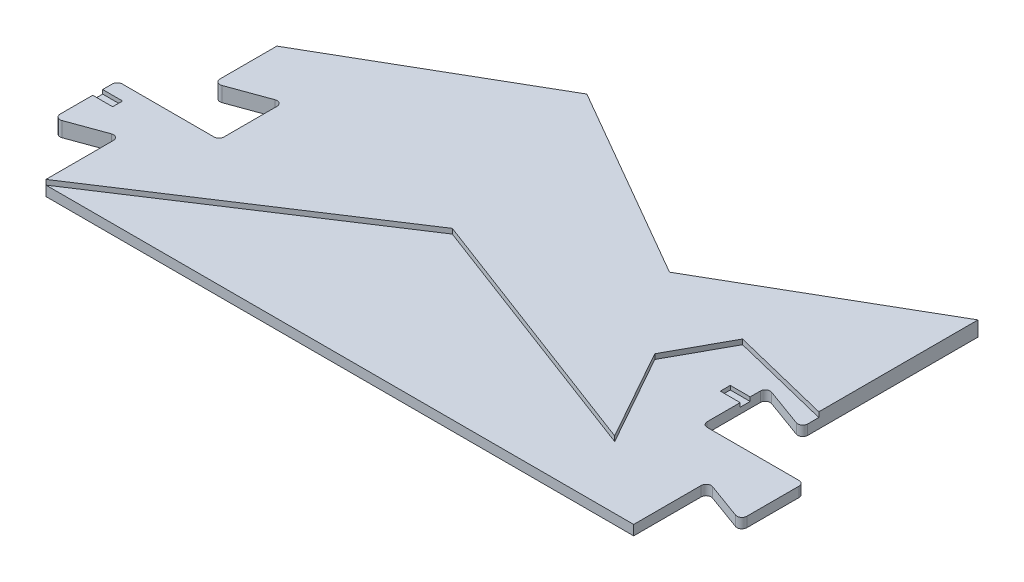
from build123d import *

# Parameters (mm, degrees)
P_IDAT_VYSUNUT_M1_DEPTH  = 3
P_IDAT_VYSUNUT_M2_DEPTH  = 2
ZAOBLIT4_R               = 1
SKICA2_W                 = 4
SKICA2_H                 = 2
ODEBRAT_VYSUNUT_M2_DEPTH = 0.8
SKICA3_W                 = 4
SKICA3_H                 = 2
ODEBRAT_VYSUNUT_M3_DEPTH = 0.8


with BuildPart() as part:
    # Skica1 → P_idat vysunut_m1 (new body)
    with BuildSketch(Plane(origin=(0, 0, 0), x_dir=(1, 0, 0), z_dir=(0, 1, 0))):
        Polygon((-118.143750166, 15), (-118.143750166, 0), (-68.779346971, 32.313398106), (-16.32734533, 12.51119421), (-26.593132493, 30.830954414), (-20.343228113, 42.230019956), (0, 37.22), (0, 69.22), (-39.317553332, 46.52), (-78.635106664, 69.22), (-118.143185584, 46.41), (-118.143185584, 33.5570142), (-107.643750166, 37.378496169), (-107.643750166, 24.278496169), (-128.093750166, 24.278496169), (-128.093750166, 11.378496169), align=None)
    extrude(amount=P_IDAT_VYSUNUT_M1_DEPTH)

    # Skica1_5 → P_idat vysunut_m2 (add)
    with BuildSketch(Plane(origin=(0, 0, 0), x_dir=(1, 0, 0), z_dir=(0, 1, 0))):
        Polygon((-68.779346971, 32.313398106), (-118.143750166, 0), (0, 0), (0, 15), (9.950504516, 11.37831254), (9.950504516, 24.27831254), (-10.5, 24.27831254), (-10.5, 37.37831254), (0, 33.55662508), (0, 37.22), (-20.343228113, 42.230019956), (-26.593132493, 30.830954414), (-16.32734533, 12.51119421), align=None)
    extrude(amount=P_IDAT_VYSUNUT_M2_DEPTH)

    # Zaoblit4
    zaoblit4_edges = [part.edges().sort_by_distance(p)[0] for p in [
        (0, 1, -33.55662508),
        (-10.5, 1, -24.27831254),
        (-10.5, 1, -37.37831254),
        (0, 1, -15),
        (9.950504516, 1, -11.37831254),
        (9.950504516, 1, -24.27831254),
        (-128.093750166, 1.5, -11.378496169),
        (-128.093750166, 1.5, -24.278496169),
        (-107.643750166, 1.5, -24.278496169),
        (-107.643750166, 1.5, -37.378496169),
        (-118.143185584, 1.5, -33.5570142),
        (-118.143750166, 1.5, -15),
    ]]
    fillet(zaoblit4_edges, radius=ZAOBLIT4_R)

    # Skica2 → Odebrat vysunut_m2 (cut)
    with BuildSketch(Plane(origin=(0, 3, 0), x_dir=(1, 0, 0), z_dir=(0, 1, 0))):
        with Locations((-126.093750166, 20.342570172)):
            Rectangle(SKICA2_W, SKICA2_H)
    extrude(amount=-ODEBRAT_VYSUNUT_M2_DEPTH, mode=Mode.SUBTRACT)

    # Skica3 → Odebrat vysunut_m3 (cut)
    with BuildSketch(Plane(origin=(0, 2, 0), x_dir=(1, 0, 0), z_dir=(0, 1, 0))):
        with Locations((-12.5, 32.914238537)):
            Rectangle(SKICA3_W, SKICA3_H)
    extrude(amount=-ODEBRAT_VYSUNUT_M3_DEPTH, mode=Mode.SUBTRACT)


solid = part.part
